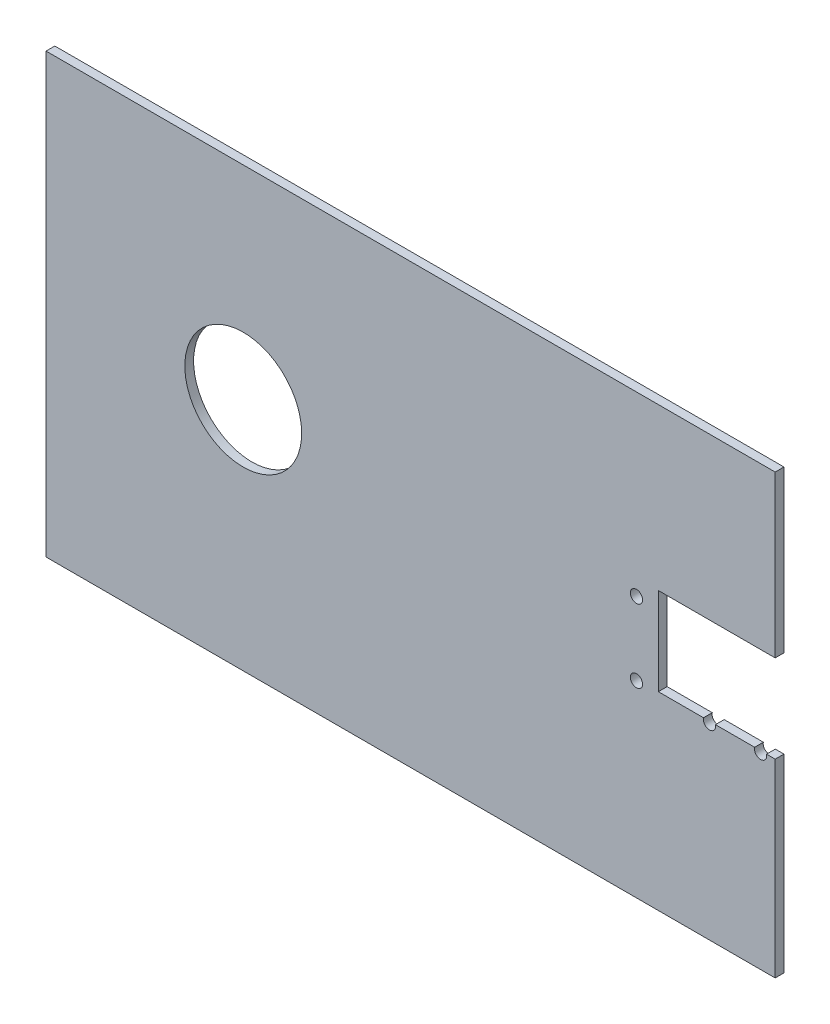
from build123d import *

# Parameters (mm, degrees)
SKETCH1_W           = 249.6
SKETCH1_H           = 150
BOSS_EXTRUDE1_DEPTH = 3
SKETCH2_R           = 20
CUT_EXTRUDE1_DEPTH  = 4
SKETCH3_W           = 40
SKETCH3_H           = 30
CUT_EXTRUDE2_DEPTH  = 5
SKETCH4_R           = 2.1
SKETCH4_R_2         = 4
CUT_EXTRUDE3_DEPTH  = 4


with BuildPart() as part:
    # Sketch1 → Boss-Extrude1 (new body)
    with BuildSketch(Plane.XY):
        with Locations((124.8, -75)):
            Rectangle(SKETCH1_W, SKETCH1_H)
    extrude(amount=BOSS_EXTRUDE1_DEPTH)

    # Sketch2 → Cut-Extrude1 (cut, through all)
    with BuildSketch(Plane.XY.offset(3)):
        with Locations((67.5, -69.58494332)):
            Circle(SKETCH2_R)
    extrude(amount=-CUT_EXTRUDE1_DEPTH, mode=Mode.SUBTRACT)

    # Sketch3 → Cut-Extrude2 (cut)
    with BuildSketch(Plane.XY.offset(3)):
        with Locations((229.6, -70.113711555)):
            Rectangle(SKETCH3_W, SKETCH3_H)
    extrude(amount=-CUT_EXTRUDE2_DEPTH, mode=Mode.SUBTRACT)

    # Sketch4 → Cut-Extrude3 (cut, through all)
    with BuildSketch(Plane.XY.offset(3)):
        with Locations((244.6, -85.613711555)):
            Circle(SKETCH4_R)
        with Locations((227.1, -85.613711555)):
            Circle(SKETCH4_R)
        with Locations((239.6, -73.113711555)):
            Circle(SKETCH4_R_2)
        with Locations((244.6, -60.613711555)):
            Circle(SKETCH4_R)
        with Locations((227.1, -60.613711555)):
            Circle(SKETCH4_R)
        with Locations((202.1, -85.613711555)):
            Circle(SKETCH4_R)
        with Locations((202.1, -60.613711555)):
            Circle(SKETCH4_R)
        with Locations((214.6, -73.113711555)):
            Circle(SKETCH4_R_2)
    extrude(amount=-CUT_EXTRUDE3_DEPTH, mode=Mode.SUBTRACT)


solid = part.part
